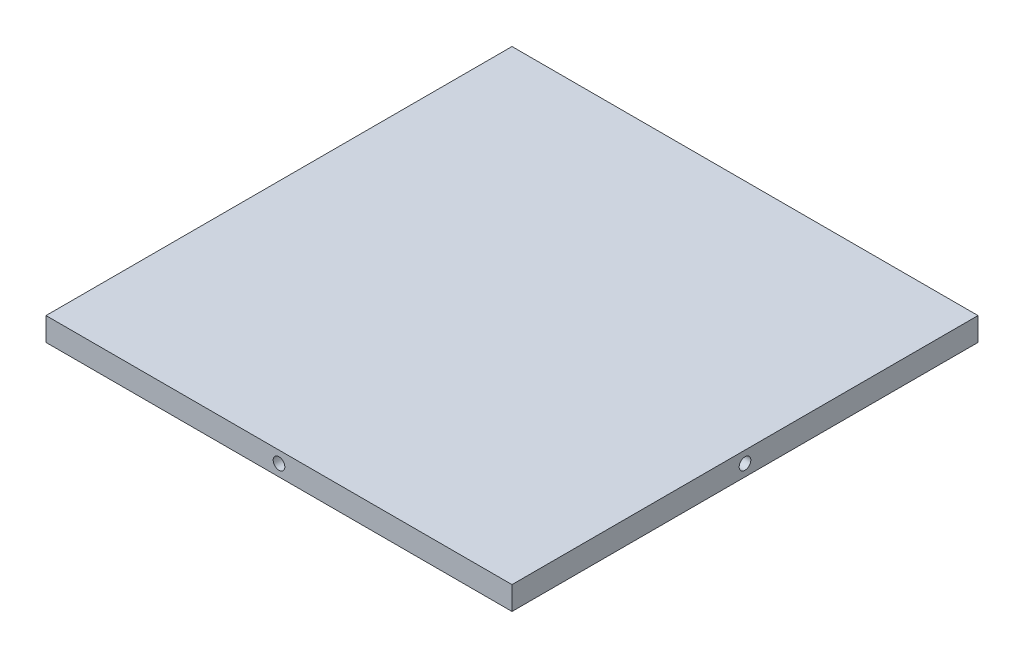
from build123d import *

# Parameters (mm, degrees)
SKETCH_1_W          = 120
SKETCH_1_H          = 120
EXTRUDE_1_DEPTH     = 6
SKETCH_2_R          = 1.5
CUT_EXTRUDE_1_DEPTH = 16
SKETCH_3_R          = 1.5
CUT_EXTRUDE_4_DEPTH = 16
SKETCH_4_R          = 1.5
CUT_EXTRUDE_5_DEPTH = 16
SKETCH_5_R          = 1.5
CUT_EXTRUDE_6_DEPTH = 16


with BuildPart() as part:
    # 草图1 → 凸台-拉伸1 (new body)
    with BuildSketch(Plane(origin=(0, 0, 0), x_dir=(1, 0, 0), z_dir=(0, 1, 0))):
        Rectangle(SKETCH_1_W, SKETCH_1_H)
    extrude(amount=EXTRUDE_1_DEPTH)

    # 草图2 → 切除-拉伸1 (cut)
    with BuildSketch(Plane(origin=(60, 0, 0), x_dir=(0, 0, -1), z_dir=(1, 0, 0))):
        with Locations((0, 3)):
            Circle(SKETCH_2_R)
    extrude(amount=-CUT_EXTRUDE_1_DEPTH, mode=Mode.SUBTRACT)

    # 草图3 → 切除-拉伸4 (cut)
    with BuildSketch(Plane(origin=(0, 0, -60), x_dir=(-1, 0, 0), z_dir=(0, 0, -1))):
        with Locations((0, 3)):
            Circle(SKETCH_3_R)
    extrude(amount=-CUT_EXTRUDE_4_DEPTH, mode=Mode.SUBTRACT)

    # 草图4 → 切除-拉伸5 (cut)
    with BuildSketch(Plane.ZY.offset(60)):
        with Locations((0, 3)):
            Circle(SKETCH_4_R)
    extrude(amount=-CUT_EXTRUDE_5_DEPTH, mode=Mode.SUBTRACT)

    # 草图5 → 切除-拉伸6 (cut)
    with BuildSketch(Plane.XY.offset(60)):
        with Locations((0, 3)):
            Circle(SKETCH_5_R)
    extrude(amount=-CUT_EXTRUDE_6_DEPTH, mode=Mode.SUBTRACT)


solid = part.part
